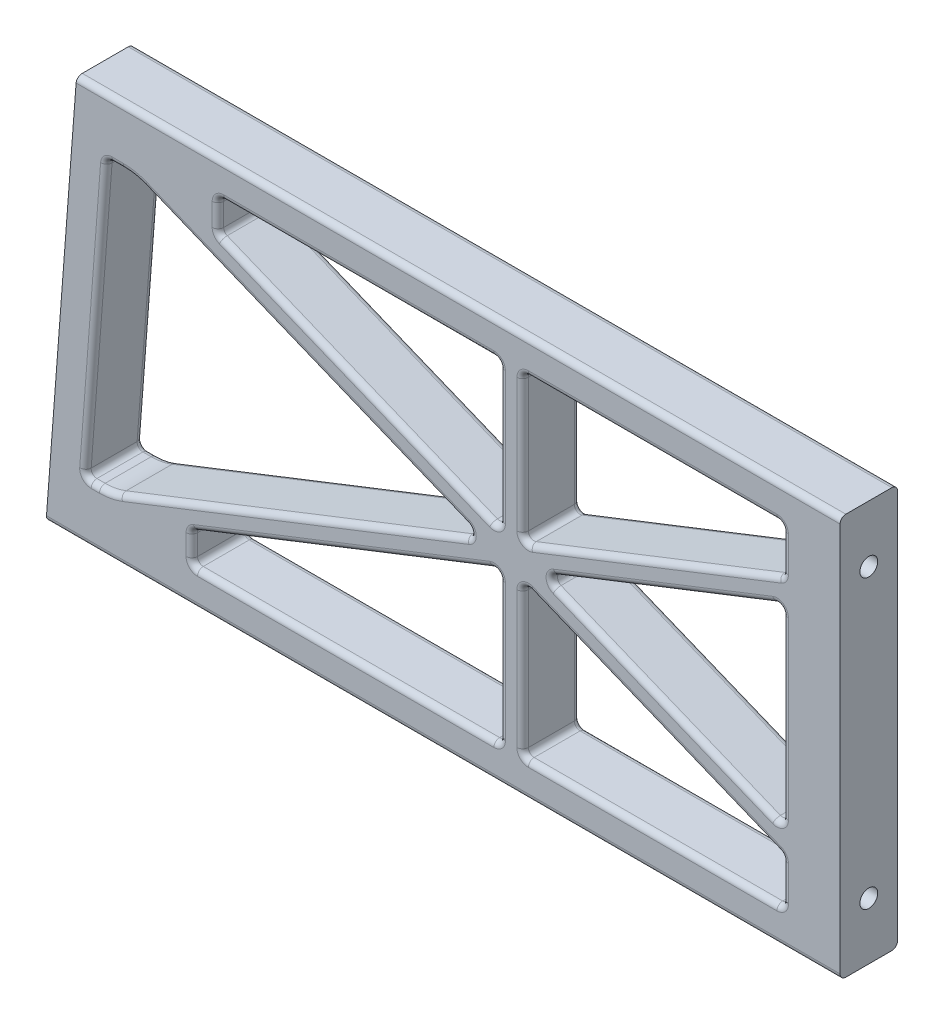
from build123d import *

# Parameters (mm, degrees)
BOSS_EXTRUDE1_DEPTH      = 5
BOSS_EXTRUDE1_DEPTH_BACK = 5
SKETCH3_W                = 33.312855189
SKETCH3_H                = 1.5
SKETCH4_W                = 42.685345657
SKETCH4_H                = 1.5
CUT_EXTRUDE1_REACH       = 140.27
SKETCH5_R                = 1.5
FILLET1_R                = 1
FILLET2_R                = 1
FILLET3_R                = 10
FILLET4_R                = 1
CUT_EXTRUDE2_REACH       = 12
SKETCH6_R                = 1.55
SKETCH6_3_R              = 3
CUT_EXTRUDE3_DEPTH       = 5
CUT_EXTRUDE3_DEPTH_BACK  = 3


with BuildPart() as part:
    # Sketch1 → Boss-Extrude1 (new body, two sides)
    with BuildSketch(Plane.XY) as boss_extrude1_sk:
        Polygon((0, 34.913615211), (0, -34.913615211), (-138.270261627, -34.913615211), (-132.959738373, 34.913615211), align=None)
        Polygon((-108.34, 28.913615211), (-59.279753957, 28.913615211), (-59.279753957, 3.322132178), (-108.34, 23.308854202), align=None, mode=Mode.SUBTRACT)
        Polygon((-10, 16.764942651), (-10, -16.754015482), (-51.894901523, 0.31360685), align=None, mode=Mode.SUBTRACT)
        Polygon((-127.702934777, 24.913615211), (-122.881201792, 24.913615211), (-62.664606391, 0.38189247), (-127.082038268, -24.913615211), (-131.492411522, -24.913615211), align=None, mode=Mode.SUBTRACT)
        Polygon((-10, -21.073214941), (-10, -28.913615211), (-55.279753957, -28.913615211), (-55.279753957, -2.626632857), align=None, mode=Mode.SUBTRACT)
        Polygon((-112.89, -23.638015205), (-112.89, -28.913615211), (-59.279753957, -28.913615211), (-59.279753957, -2.58628509), align=None, mode=Mode.SUBTRACT)
        Polygon((-55.279753957, 28.913615211), (-55.279753957, 3.28178441), (-10, 21.062287771), (-10, 28.913615211), align=None, mode=Mode.SUBTRACT)
    extrude(amount=BOSS_EXTRUDE1_DEPTH)
    extrude(boss_extrude1_sk.sketch, amount=-BOSS_EXTRUDE1_DEPTH_BACK)

    # Sketch3 → Cut-Revolve2 (revolve, cut)
    with BuildSketch(Plane.XY):
        with Locations((-129.996427595, 30.663615211)):
            Rectangle(SKETCH3_W, SKETCH3_H)
    revolve(axis=Axis((-152.822662449, 29.913615211, 0), (1, 0, 0)), mode=Mode.SUBTRACT)

    # Sketch4 → Cut-Revolve3 (revolve, cut)
    with BuildSketch(Plane.XY):
        with Locations((-139.232672829, -29.163615211)):
            Rectangle(SKETCH4_W, SKETCH4_H)
    revolve(axis=Axis((-173.755810418, -29.913615211, 0), (1, 0, 0)), mode=Mode.SUBTRACT)

    # Sketch5 → Cut-Extrude1 (cut, up to next)
    with BuildSketch(Plane(origin=(0, 0, 0), x_dir=(0, 0, -1), z_dir=(1, 0, 0)), mode=Mode.PRIVATE) as cut_extrude1_sk1:
        with Locations((0, 25)):
            Circle(SKETCH5_R)
    cut_extrude1_tool1 = extrude(cut_extrude1_sk1.sketch, amount=-CUT_EXTRUDE1_REACH, mode=Mode.PRIVATE) & part.part
    add(cut_extrude1_tool1.solids().sort_by_distance((0, 25, 0))[0], mode=Mode.SUBTRACT)
    # Sketch5 → Cut-Extrude1 (cut, up to next)
    with BuildSketch(Plane(origin=(0, 0, 0), x_dir=(0, 0, -1), z_dir=(1, 0, 0)), mode=Mode.PRIVATE) as cut_extrude1_sk2:
        with Locations((0, -25)):
            Circle(SKETCH5_R)
    cut_extrude1_tool2 = extrude(cut_extrude1_sk2.sketch, amount=-CUT_EXTRUDE1_REACH, mode=Mode.PRIVATE) & part.part
    add(cut_extrude1_tool2.solids().sort_by_distance((0, -25, 0))[0], mode=Mode.SUBTRACT)

    # Fillet1
    fillet1_edges = [part.edges().sort_by_distance(p)[0] for p in [
        (-69.135130814, -34.913615211, -5),
        (-66.479869186, 34.913615211, -5),
        (-66.479869186, 34.913615211, 5),
        (-69.135130814, -34.913615211, 5),
    ]]
    fillet(fillet1_edges, radius=FILLET1_R)

    # Fillet2
    fillet2_edges = [part.edges().sort_by_distance(p)[0] for p in [
        (-112.89, -23.638015205, 0),
        (-59.279753957, -2.58628509, 0),
        (-59.279753957, -28.913615211, 0),
        (-112.89, -28.913615211, 0),
        (-131.492411522, -24.913615211, 0),
        (-127.702934777, 24.913615211, 0),
        (-62.664606391, 0.38189247, 0),
        (-10, -28.913615211, 0),
        (-55.279753957, -28.913615211, 0),
        (-55.279753957, -2.626632857, 0),
        (-10, -21.073214941, 0),
        (-108.34, 23.308854202, 0),
        (-108.34, 28.913615211, 0),
        (-59.279753957, 28.913615211, 0),
        (-59.279753957, 3.322132178, 0),
        (-10, 21.062287771, 0),
        (-55.279753957, 3.28178441, 0),
        (-55.279753957, 28.913615211, 0),
        (-10, 28.913615211, 0),
        (-10, -16.754015482, 0),
        (-51.894901523, 0.31360685, 0),
        (-10, 16.764942651, 0),
    ]]
    fillet(fillet2_edges, radius=FILLET2_R)

    # Fillet3
    fillet3_edges = [part.edges().sort_by_distance(p)[0] for p in [
        (-122.881201792, 24.913615211, 0),
        (-127.082038268, -24.913615211, 0),
    ]]
    fillet(fillet3_edges, radius=FILLET3_R)

    # Fillet4
    fillet4_edges = [part.edges().sort_by_distance(p)[0] for p in [
        (-32.639876978, 28.913615211, 5),
        (-32.639876978, 28.913615211, -5),
        (-10, 24.828779084, 5),
        (-10, 24.828779084, -5),
        (-55.279753957, 16.331208498, 5),
        (-55.279753957, 16.331208498, -5),
        (-32.274366568, 12.315565119, 5),
        (-32.274366568, 12.315565119, -5),
        (-30.466748063, 8.728037612, 5),
        (-30.466748063, 8.728037612, -5),
        (-10, 0.015550527, 5),
        (-10, 0.015550527, -5),
        (-30.478521821, -8.41124193, 5),
        (-30.478521821, -8.41124193, -5),
        (-32.26259281, -12.003626222, 5),
        (-32.26259281, -12.003626222, -5),
        (-10, -24.829619311, 5),
        (-10, -24.829619311, -5),
        (-32.639876978, -28.913615211, 5),
        (-32.639876978, -28.913615211, -5),
        (-55.279753957, -16.013719664, 5),
        (-55.279753957, -16.013719664, -5),
        (-86.450387389, -13.255679175, 5),
        (-86.450387389, -13.255679175, -5),
        (-59.279753957, -15.983458838, 5),
        (-59.279753957, -15.983458838, -5),
        (-86.084876978, -28.913615211, 5),
        (-86.084876978, -28.913615211, -5),
        (-112.89, -26.1166428, 5),
        (-112.89, -26.1166428, -5),
        (-93.023454746, 12.749826021, 5),
        (-93.023454746, 12.749826021, -5),
        (-59.279753957, 16.361469324, 5),
        (-59.279753957, 16.361469324, -5),
        (-84.187161147, 13.469195513, 5),
        (-84.187161147, 13.469195513, -5),
        (-83.809876978, 28.913615211, 5),
        (-83.809876978, 28.913615211, -5),
        (-108.34, 25.947438942, 5),
        (-108.34, 25.947438942, -5),
        (-129.694277094, -24.913615211, 5),
        (-129.694277094, -24.913615211, -5),
        (-129.591905848, 0.075833333, 5),
        (-129.591905848, 0.075833333, -5),
        (-10.292893219, 28.620721992, 5),
        (-10.292893219, 28.620721992, -5),
        (-54.986860738, 28.620721992, 5),
        (-54.986860738, 28.620721992, -5),
        (-54.842998836, 3.92251176, 5),
        (-54.842998836, 3.92251176, -5),
        (-10.173709975, 21.180698076, 5),
        (-10.173709975, 21.180698076, -5),
        (-10.43675512, 16.124215301, 5),
        (-10.43675512, 16.124215301, -5),
        (-10.442005452, -16.096668837, 5),
        (-10.442005452, -16.096668837, -5),
        (-50.202455205, 0.302875846, 5),
        (-50.202455205, 0.302875846, -5),
        (-10.170155386, -21.187628863, 5),
        (-10.170155386, -21.187628863, -5),
        (-10.292893219, -28.620721992, 5),
        (-10.292893219, -28.620721992, -5),
        (-54.986860738, -28.620721992, 5),
        (-54.986860738, -28.620721992, -5),
        (-54.837748505, -3.283979502, 5),
        (-54.837748505, -3.283979502, -5),
        (-59.716509077, -3.227012439, 5),
        (-59.716509077, -3.227012439, -5),
        (-59.572647175, -28.620721992, 5),
        (-59.572647175, -28.620721992, -5),
        (-112.597106781, -28.620721992, 5),
        (-112.597106781, -28.620721992, -5),
        (-112.716290025, -23.75642551, 5),
        (-112.716290025, -23.75642551, -5),
        (-64.357052708, 0.392623474, 5),
        (-64.357052708, 0.392623474, -5),
        (-59.721759408, 3.979478822, 5),
        (-59.721759408, 3.979478822, -5),
        (-59.572647175, 28.620721992, 5),
        (-59.572647175, 28.620721992, -5),
        (-108.047106781, 28.620721992, 5),
        (-108.047106781, 28.620721992, -5),
        (-108.169844614, 23.423268124, 5),
        (-108.169844614, 23.423268124, -5),
        (-131.146899413, -24.593382328, 5),
        (-131.146899413, -24.593382328, -5),
        (-127.455866411, 24.647043235, 5),
        (-127.455866411, 24.647043235, -5),
        (-125.808051015, 24.913615211, 5),
        (-125.808051015, 24.913615211, -5),
        (-95.155750444, -12.376765552, 5),
        (-95.155750444, -12.376765552, -5),
        (-122.917732483, 24.727120042, 5),
        (-122.917732483, 24.727120042, -5),
        (-127.11507274, -24.73911075, 5),
        (-127.11507274, -24.73911075, -5),
    ]]
    fillet(fillet4_edges, radius=FILLET4_R)

    # Mirror1: part across plane


with BuildPart() as part_1:
    add(part.part)
    add(part.part.mirror(Plane(origin=(0, 0, 0), x_dir=(0, 0, 1), z_dir=(1, 0, 0))))

    # Split1
    split(bisect_by=Plane(origin=(0, 0, 0), x_dir=(0, 0, 1), z_dir=(1, 0, 0)), keep=Keep.BOTTOM)

    # Sketch6 → Cut-Extrude2 (cut, up to next)
    with BuildSketch(Plane.ZY.offset(10), mode=Mode.PRIVATE) as cut_extrude2_sk1:
        with Locations((0, 25)):
            Circle(SKETCH6_R)
    cut_extrude2_tool1 = extrude(cut_extrude2_sk1.sketch, amount=-CUT_EXTRUDE2_REACH, mode=Mode.PRIVATE) & part_1.part
    add(cut_extrude2_tool1.solids().sort_by_distance((-10, 25, 0))[0], mode=Mode.SUBTRACT)
    # Sketch6 → Cut-Extrude2 (cut, up to next)
    with BuildSketch(Plane.ZY.offset(10), mode=Mode.PRIVATE) as cut_extrude2_sk2:
        with Locations((0, -25)):
            Circle(SKETCH6_R)
    cut_extrude2_tool2 = extrude(cut_extrude2_sk2.sketch, amount=-CUT_EXTRUDE2_REACH, mode=Mode.PRIVATE) & part_1.part
    add(cut_extrude2_tool2.solids().sort_by_distance((-10, -25, 0))[0], mode=Mode.SUBTRACT)

    # Sketch6_3 → Cut-Extrude3 (cut, two sides)
    with BuildSketch(Plane.ZY.offset(10)) as cut_extrude3_sk:
        with Locations((0, 25)):
            Circle(SKETCH6_3_R)
        with Locations((0, -25)):
            Circle(SKETCH6_3_R)
    extrude(amount=CUT_EXTRUDE3_DEPTH, mode=Mode.SUBTRACT)
    extrude(cut_extrude3_sk.sketch, amount=-CUT_EXTRUDE3_DEPTH_BACK, mode=Mode.SUBTRACT)


solid = part_1.part
